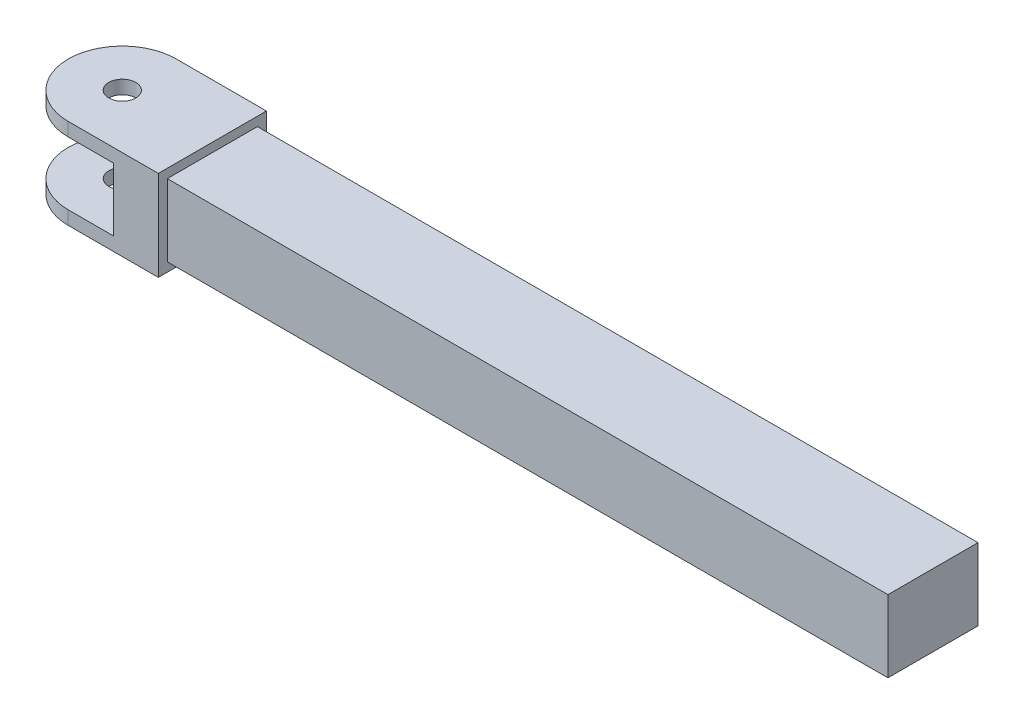
from build123d import *

# Parameters (mm, degrees)
SZKIC1_R                    = 1.5
DODANIE_WYCI_GNI_CIE1_DEPTH = 10
SZKIC2_W                    = 22
SZKIC2_H                    = 7
WYTNIJ_WYCI_GNI_CIE1_DEPTH  = 13
SZKIC3_OUTSIDE_W            = 33.452
SZKIC3_OUTSIDE_H            = 31.452
SZKIC3_OUTSIDE_W_2          = 10
SZKIC3_OUTSIDE_H_2          = 8
WYTNIJ_WYCI_GNI_CIE2_DEPTH  = 80


with BuildPart() as part:
    # Szkic1 → Dodanie-wyciągnięcie1 (new body)
    with BuildSketch(Plane(origin=(0, 0, 0), x_dir=(1, 0, 0), z_dir=(0, 1, 0))):
        with BuildLine():
            Line((90, 6), (90, -6))
            Line((90, -6), (0, -6))
            ThreePointArc((0, -6), (-6, 0), (0, 6))
            Line((0, 6), (90, 6))
        make_face()
        Circle(SZKIC1_R, mode=Mode.SUBTRACT)
    extrude(amount=DODANIE_WYCI_GNI_CIE1_DEPTH)

    # Szkic2 → Wytnij-wyciągnięcie1 (cut, through all)
    with BuildSketch(Plane(origin=(0, 0, -6), x_dir=(-1, 0, 0), z_dir=(0, 0, -1))):
        with Locations((6, 5)):
            Rectangle(SZKIC2_W, SZKIC2_H)
    extrude(amount=-WYTNIJ_WYCI_GNI_CIE1_DEPTH, mode=Mode.SUBTRACT)

    # Szkic3 outside → Wytnij-wyciągnięcie2 (cut)
    with BuildSketch(Plane(origin=(90, 0, 0), x_dir=(0, 0, -1), z_dir=(1, 0, 0))):
        with Locations((0, 5)):
            Rectangle(SZKIC3_OUTSIDE_W, SZKIC3_OUTSIDE_H)
        with Locations((0, 5)):
            Rectangle(SZKIC3_OUTSIDE_W_2, SZKIC3_OUTSIDE_H_2, mode=Mode.SUBTRACT)
    extrude(amount=-WYTNIJ_WYCI_GNI_CIE2_DEPTH, mode=Mode.SUBTRACT)


solid = part.part
